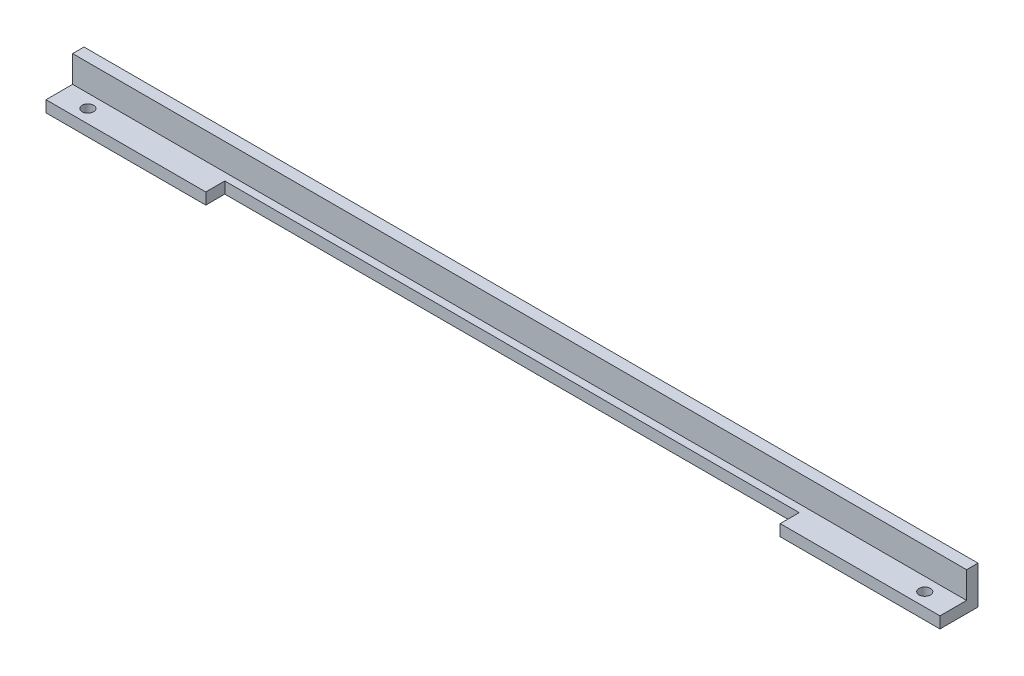
from build123d import *

# Parameters (mm, degrees)
EXTRUDE_1_DEPTH     = 235
SKETCH_3_R          = 1.5
CUT_EXTRUDE_1_DEPTH = 10
SKETCH_4_W          = 151
SKETCH_4_H          = 3
CUT_EXTRUDE_2_DEPTH = 5


with BuildPart() as part:
    # Эскиз1 → Бобышка-Вытянуть1 (new body)
    with BuildSketch(Plane(origin=(0, 0, 0), x_dir=(0, 0, -1), z_dir=(1, 0, 0))):
        Polygon((0, 0), (-10, 0), (-10, 3), (-3, 3), (-3, 10), (0, 10), align=None)
    extrude(amount=EXTRUDE_1_DEPTH)

    # Эскиз3 → Вырез-Вытянуть1 (cut)
    with BuildSketch(Plane(origin=(0, 3, 0), x_dir=(1, 0, 0), z_dir=(0, 1, 0))):
        with Locations((7.5, -6.5)):
            Circle(SKETCH_3_R)
        with Locations((227.5, -6.5)):
            Circle(SKETCH_3_R)
    extrude(amount=-CUT_EXTRUDE_1_DEPTH, mode=Mode.SUBTRACT)

    # Эскиз4 → Вырез-Вытянуть2 (cut)
    with BuildSketch(Plane.XY.offset(10)):
        with Locations((117.5, 1.5)):
            Rectangle(SKETCH_4_W, SKETCH_4_H)
    extrude(amount=-CUT_EXTRUDE_2_DEPTH, mode=Mode.SUBTRACT)


solid = part.part
